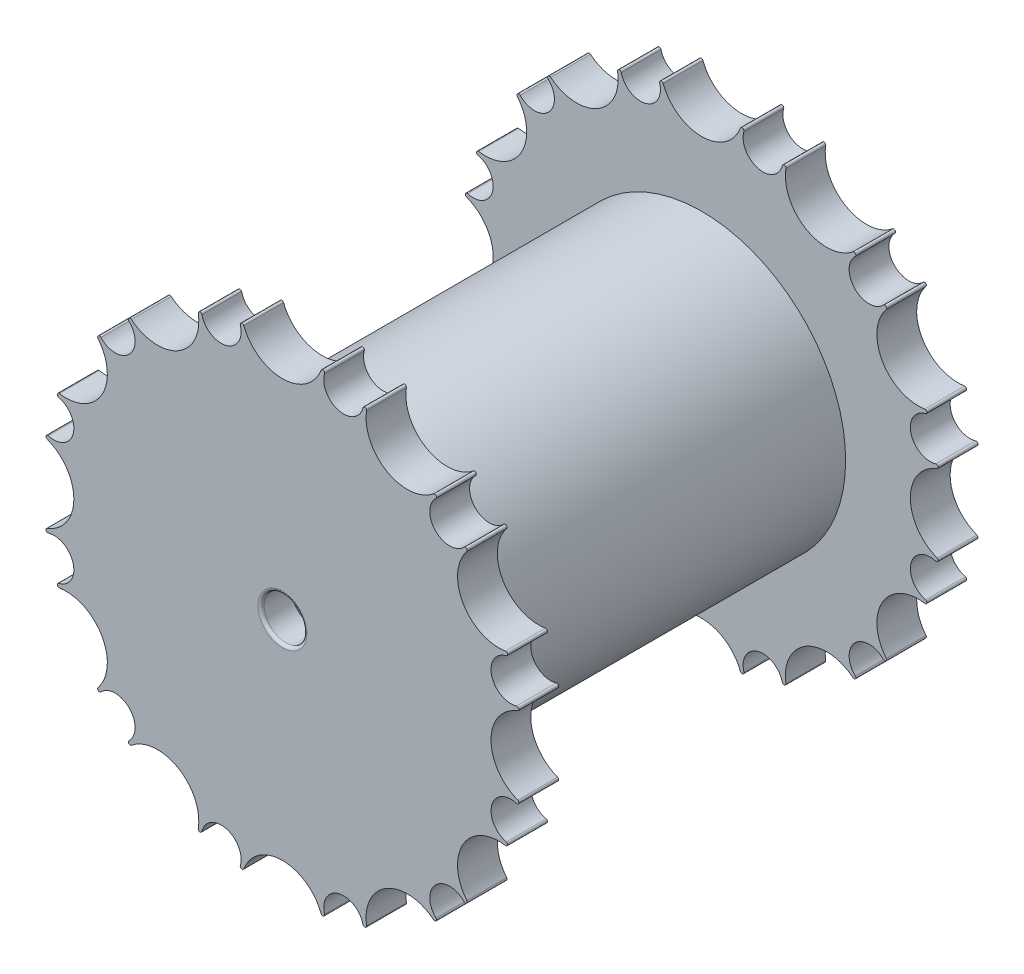
from build123d import *

# Parameters (mm, degrees)
BOSS_EXTRUDE1_DEPTH = 3.25
SKETCH5_R           = 20
SKETCH5_R_2         = 10
BOSS_EXTRUDE2_DEPTH = 1
BOSS_EXTRUDE3_DEPTH = 1.5
BOSS_EXTRUDE4_START = -31
SKETCH9_R           = 23.5
BOSS_EXTRUDE4_DEPTH = 62
SKETCH12_R          = 3.35
CUT_EXTRUDE1_DEPTH  = 5
SKETCH11_R          = 3.5
CUT_EXTRUDE2_DEPTH  = 5
FILLET1_R           = 0.5


with BuildPart() as part:
    # Sketch4 → Boss-Extrude1 (new body, symmetric)
    with BuildSketch(Plane.XY):
        with BuildLine():
            ThreePointArc((-24.679485793, 30.123197595), (-25.095377084, 30.089266142), (-25.07747192, 29.672377291))
            ThreePointArc((-25.07747192, 29.672377291), (-24.070735897, 27.35898907), (-25.022411037, 25.022411037))
            ThreePointArc((-25.022411037, 25.022411037), (-27.35898907, 24.070735897), (-29.672377291, 25.07747192))
            ThreePointArc((-29.672377291, 25.07747192), (-30.089266142, 25.095377084), (-30.123197595, 24.679485793))
            ThreePointArc((-30.123197595, 24.679485793), (-29.505925513, 17.035254038), (-36.434660446, 13.747711464))
            ThreePointArc((-36.434660446, 13.747711464), (-36.777867143, 13.510380319), (-36.553916391, 13.158296564))
            ThreePointArc((-36.553916391, 13.158296564), (-34.52536331, 11.658211608), (-34.18124914, 9.158838103))
            ThreePointArc((-34.18124914, 9.158838103), (-35.728947505, 7.16637424), (-38.235768484, 6.8815391))
            ThreePointArc((-38.235768484, 6.8815391), (-38.605757403, 6.688601001), (-38.427197257, 6.311462851))
            ThreePointArc((-38.427197257, 6.311462851), (-34.070508076, 0), (-38.427197257, -6.311462851))
            ThreePointArc((-38.427197257, -6.311462851), (-38.605757403, -6.688601001), (-38.235768484, -6.8815391))
            ThreePointArc((-38.235768484, -6.8815391), (-35.728947505, -7.16637424), (-34.18124914, -9.158838103))
            ThreePointArc((-34.18124914, -9.158838103), (-34.52536331, -11.658211608), (-36.553916391, -13.158296564))
            ThreePointArc((-36.553916391, -13.158296564), (-36.777867143, -13.510380319), (-36.434660446, -13.747711464))
            ThreePointArc((-36.434660446, -13.747711464), (-29.505925513, -17.035254038), (-30.123197595, -24.679485793))
            ThreePointArc((-30.123197595, -24.679485793), (-30.089266142, -25.095377084), (-29.672377291, -25.07747192))
            ThreePointArc((-29.672377291, -25.07747192), (-27.35898907, -24.070735897), (-25.022411037, -25.022411037))
            ThreePointArc((-25.022411037, -25.022411037), (-24.070735897, -27.35898907), (-25.07747192, -29.672377291))
            ThreePointArc((-25.07747192, -29.672377291), (-25.095377084, -30.089266142), (-24.679485793, -30.123197595))
            ThreePointArc((-24.679485793, -30.123197595), (-17.035254038, -29.505925513), (-13.747711464, -36.434660446))
            ThreePointArc((-13.747711464, -36.434660446), (-13.510380319, -36.777867143), (-13.158296564, -36.553916391))
            ThreePointArc((-13.158296564, -36.553916391), (-11.658211608, -34.52536331), (-9.158838103, -34.18124914))
            ThreePointArc((-9.158838103, -34.18124914), (-7.16637424, -35.728947505), (-6.8815391, -38.235768484))
            ThreePointArc((-6.8815391, -38.235768484), (-6.688601001, -38.605757403), (-6.311462851, -38.427197257))
            ThreePointArc((-6.311462851, -38.427197257), (0, -34.070508076), (6.311462851, -38.427197257))
            ThreePointArc((6.311462851, -38.427197257), (6.688601001, -38.605757403), (6.8815391, -38.235768484))
            ThreePointArc((6.8815391, -38.235768484), (7.16637424, -35.728947505), (9.158838103, -34.18124914))
            ThreePointArc((9.158838103, -34.18124914), (11.658211608, -34.52536331), (13.158296564, -36.553916391))
            ThreePointArc((13.158296564, -36.553916391), (13.510380319, -36.777867143), (13.747711464, -36.434660446))
            ThreePointArc((13.747711464, -36.434660446), (17.035254038, -29.505925513), (24.679485793, -30.123197595))
            ThreePointArc((24.679485793, -30.123197595), (25.095377084, -30.089266142), (25.07747192, -29.672377291))
            ThreePointArc((25.07747192, -29.672377291), (24.070735897, -27.35898907), (25.022411037, -25.022411037))
            ThreePointArc((25.022411037, -25.022411037), (27.35898907, -24.070735897), (29.672377291, -25.07747192))
            ThreePointArc((29.672377291, -25.07747192), (30.089266142, -25.095377084), (30.123197595, -24.679485793))
            ThreePointArc((30.123197595, -24.679485793), (29.505925513, -17.035254038), (36.434660446, -13.747711464))
            ThreePointArc((36.434660446, -13.747711464), (36.777867143, -13.510380319), (36.553916391, -13.158296564))
            ThreePointArc((36.553916391, -13.158296564), (34.52536331, -11.658211608), (34.18124914, -9.158838103))
            ThreePointArc((34.18124914, -9.158838103), (35.728947505, -7.16637424), (38.235768484, -6.8815391))
            ThreePointArc((38.235768484, -6.8815391), (38.605757403, -6.688601001), (38.427197257, -6.311462851))
            ThreePointArc((38.427197257, -6.311462851), (34.070508076, 0), (38.427197257, 6.311462851))
            ThreePointArc((38.427197257, 6.311462851), (38.605757403, 6.688601001), (38.235768484, 6.8815391))
            ThreePointArc((38.235768484, 6.8815391), (35.728947505, 7.16637424), (34.18124914, 9.158838103))
            ThreePointArc((34.18124914, 9.158838103), (34.52536331, 11.658211608), (36.553916391, 13.158296564))
            ThreePointArc((36.553916391, 13.158296564), (36.777867143, 13.510380319), (36.434660446, 13.747711464))
            ThreePointArc((36.434660446, 13.747711464), (29.505925513, 17.035254038), (30.123197595, 24.679485793))
            ThreePointArc((30.123197595, 24.679485793), (30.089266142, 25.095377084), (29.672377291, 25.07747192))
            ThreePointArc((29.672377291, 25.07747192), (27.35898907, 24.070735897), (25.022411037, 25.022411037))
            ThreePointArc((25.022411037, 25.022411037), (24.070735897, 27.35898907), (25.07747192, 29.672377291))
            ThreePointArc((25.07747192, 29.672377291), (25.095377084, 30.089266142), (24.679485793, 30.123197595))
            ThreePointArc((24.679485793, 30.123197595), (17.035254038, 29.505925513), (13.747711464, 36.434660446))
            ThreePointArc((13.747711464, 36.434660446), (13.510380319, 36.777867143), (13.158296564, 36.553916391))
            ThreePointArc((13.158296564, 36.553916391), (11.658211608, 34.52536331), (9.158838103, 34.18124914))
            ThreePointArc((9.158838103, 34.18124914), (7.16637424, 35.728947505), (6.8815391, 38.235768484))
            ThreePointArc((6.8815391, 38.235768484), (6.688601001, 38.605757403), (6.311462851, 38.427197257))
            ThreePointArc((6.311462851, 38.427197257), (0, 34.070508076), (-6.311462851, 38.427197257))
            ThreePointArc((-6.311462851, 38.427197257), (-6.688601001, 38.605757403), (-6.8815391, 38.235768484))
            ThreePointArc((-6.8815391, 38.235768484), (-7.16637424, 35.728947505), (-9.158838103, 34.18124914))
            ThreePointArc((-9.158838103, 34.18124914), (-11.658211608, 34.52536331), (-13.158296564, 36.553916391))
            ThreePointArc((-13.158296564, 36.553916391), (-13.510380319, 36.777867143), (-13.747711464, 36.434660446))
            ThreePointArc((-13.747711464, 36.434660446), (-17.035254038, 29.505925513), (-24.679485793, 30.123197595))
        make_face()
    extrude(amount=BOSS_EXTRUDE1_DEPTH, both=True)



with BuildPart() as body_2:
    # Sketch5 → Boss-Extrude2 (new body, symmetric)
    with BuildSketch(Plane.XY):
        Circle(SKETCH5_R)
        Circle(SKETCH5_R_2, mode=Mode.SUBTRACT)
    extrude(amount=BOSS_EXTRUDE2_DEPTH, both=True)


with BuildPart() as part_1:
    add(part.part)

    add(body_2.part)  # Boss-Extrude3 merges body 2
    # Sketch6 → Boss-Extrude3 (add)
    with BuildSketch(Plane.XY.offset(1)):
        with BuildLine():
            Line((0.75, 29.990623535), (0.75, 19.990623535))
            ThreePointArc((0.75, 19.990623535), (0, 19.240623535), (-0.75, 19.990623535))
            Line((-0.75, 19.990623535), (-0.75, 29.990623535))
            ThreePointArc((-0.75, 29.990623535), (0, 30.740623535), (0.75, 29.990623535))
        make_face()
        with BuildLine():
            Line((25.597641856, 15.64483082), (16.937387819, 10.64483082))
            ThreePointArc((16.937387819, 10.64483082), (16.662868766, 9.620311767), (17.687387819, 9.345792715))
            Line((17.687387819, 9.345792715), (26.347641856, 14.345792715))
            ThreePointArc((26.347641856, 14.345792715), (26.622160909, 15.370311767), (25.597641856, 15.64483082))
        make_face()
        with BuildLine():
            Line((26.347641856, -14.345792715), (17.687387819, -9.345792715))
            ThreePointArc((17.687387819, -9.345792715), (16.662868766, -9.620311767), (16.937387819, -10.64483082))
            Line((16.937387819, -10.64483082), (25.597641856, -15.64483082))
            ThreePointArc((25.597641856, -15.64483082), (26.622160909, -15.370311767), (26.347641856, -14.345792715))
        make_face()
        with BuildLine():
            Line((0.75, -29.990623535), (0.75, -19.990623535))
            ThreePointArc((0.75, -19.990623535), (0, -19.240623535), (-0.75, -19.990623535))
            Line((-0.75, -19.990623535), (-0.75, -29.990623535))
            ThreePointArc((-0.75, -29.990623535), (0, -30.740623535), (0.75, -29.990623535))
        make_face()
        with BuildLine():
            Line((-25.597641856, -15.64483082), (-16.937387819, -10.64483082))
            ThreePointArc((-16.937387819, -10.64483082), (-16.662868766, -9.620311767), (-17.687387819, -9.345792715))
            Line((-17.687387819, -9.345792715), (-26.347641856, -14.345792715))
            ThreePointArc((-26.347641856, -14.345792715), (-26.622160909, -15.370311767), (-25.597641856, -15.64483082))
        make_face()
        with BuildLine():
            Line((-26.347641856, 14.345792715), (-17.687387819, 9.345792715))
            ThreePointArc((-17.687387819, 9.345792715), (-16.662868766, 9.620311767), (-16.937387819, 10.64483082))
            Line((-16.937387819, 10.64483082), (-25.597641856, 15.64483082))
            ThreePointArc((-25.597641856, 15.64483082), (-26.622160909, 15.370311767), (-26.347641856, 14.345792715))
        make_face()
    extrude(amount=-BOSS_EXTRUDE3_DEPTH)


with BuildPart() as body_2_2:
    # Mirror2: mirrored copy
    add(part_1.part.mirror(Plane.XY.offset(34.25)))


with BuildPart() as part_2:
    add(part_1.part)

    add(body_2_2.part)  # Boss-Extrude4 merges body 2 2
    # Sketch9 → Boss-Extrude4 (add)
    with BuildSketch(Plane.XY.offset(34.25).offset(BOSS_EXTRUDE4_START)):
        Circle(SKETCH9_R)
    extrude(amount=BOSS_EXTRUDE4_DEPTH)

    # Sketch12 → Cut-Extrude1 (cut)
    with BuildSketch(Plane(origin=(0, 0, -3.25), x_dir=(-1, 0, 0), z_dir=(0, 0, -1))):
        Circle(SKETCH12_R)
    extrude(amount=-CUT_EXTRUDE1_DEPTH, mode=Mode.SUBTRACT)

    # Sketch11 → Cut-Extrude2 (cut)
    with BuildSketch(Plane.XY.offset(71.75)):
        Circle(SKETCH11_R)
    extrude(amount=-CUT_EXTRUDE2_DEPTH, mode=Mode.SUBTRACT)

    # Fillet1
    fillet1_edges = [part_2.edges().sort_by_distance(p)[0] for p in [
        (3.35, 0, -3.25),
        (-3.5, 0, 71.75),
    ]]
    fillet(fillet1_edges, radius=FILLET1_R)


solid = part_2.part
